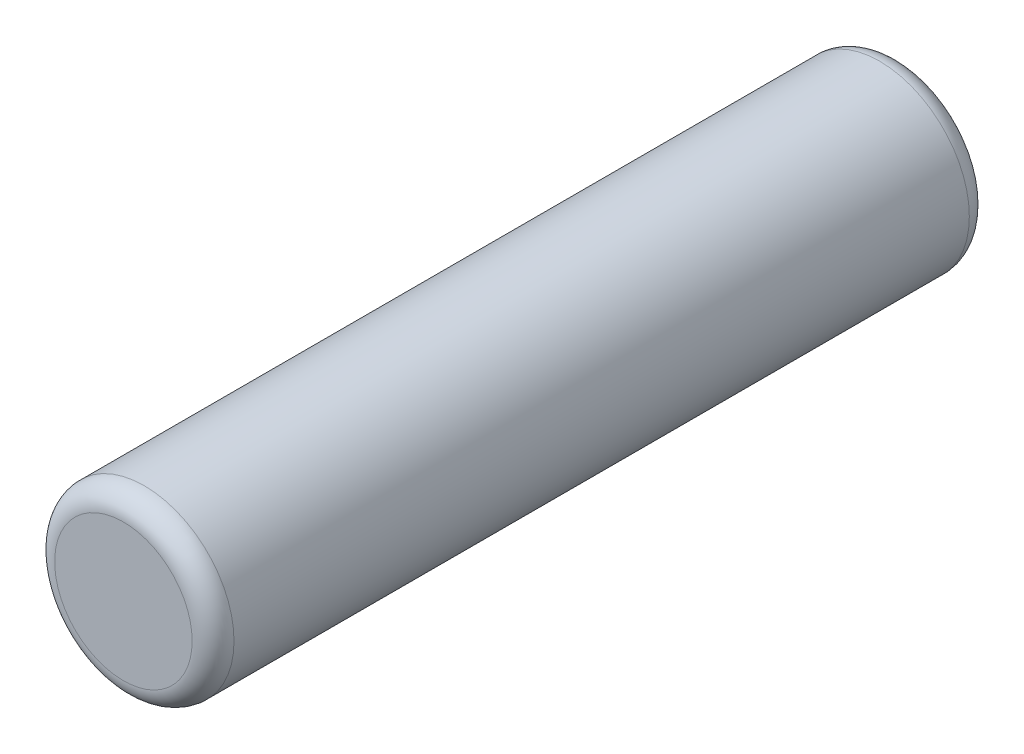
from build123d import *

# Parameters (mm, degrees)
SKETCH1_R           = 1.5
BOSS_EXTRUDE1_DEPTH = 6.5
FILLET1_R           = 0.35


with BuildPart() as part:
    # Sketch1 → Boss-Extrude1 (new body, symmetric)
    with BuildSketch(Plane.XY):
        Circle(SKETCH1_R)
    extrude(amount=BOSS_EXTRUDE1_DEPTH, both=True)

    # Fillet1
    fillet1_edges = [part.edges().sort_by_distance(p)[0] for p in [
        (-1.5, 0, -6.5),
        (-1.5, 0, 6.5),
    ]]
    fillet(fillet1_edges, radius=FILLET1_R)


solid = part.part
